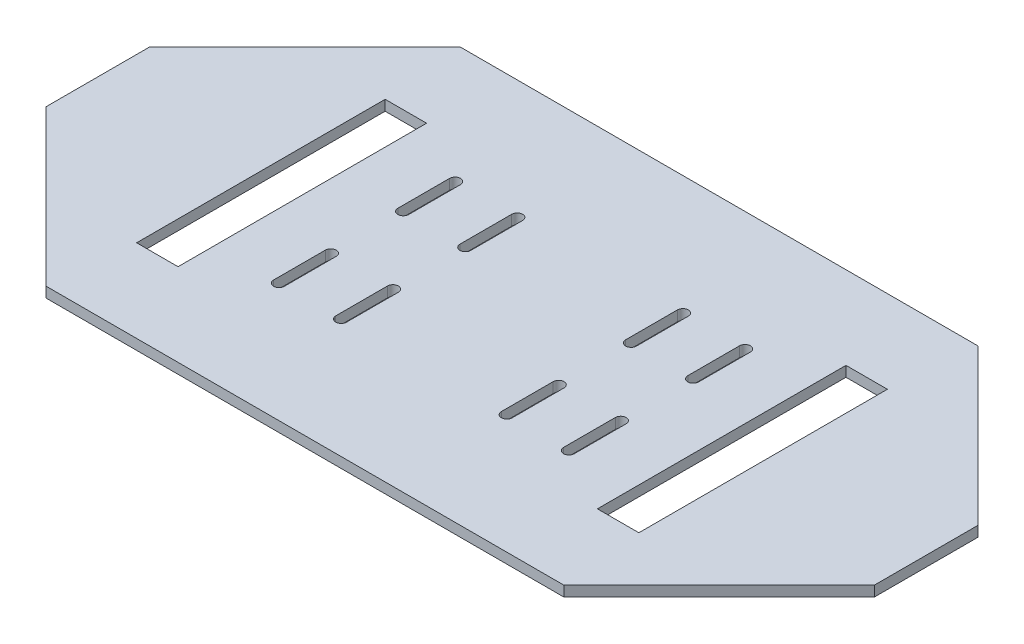
from build123d import *

# Parameters (mm, degrees)
ESQUISSE1_W             = 160
ESQUISSE1_H             = 80
BOSS_EXTRU_1_DEPTH      = 2
ENL_V_MAT_EXTRU_2_DEPTH = 2
ENL_V_MAT_EXTRU_3_DEPTH = 2
ENL_V_MAT_EXTRU_4_REACH = 4
ESQUISSE8_W             = 8
ESQUISSE8_H             = 48


with BuildPart() as part:
    # Esquisse1 → Boss.-Extru.1 (new body)
    with BuildSketch(Plane(origin=(0, 0, 0), x_dir=(1, 0, 0), z_dir=(0, 1, 0))):
        with Locations((80, 40)):
            Rectangle(ESQUISSE1_W, ESQUISSE1_H)
    extrude(amount=BOSS_EXTRU_1_DEPTH)

    # Esquisse2 → Enlèv. mat.-Extru.2 (cut)
    with BuildSketch(Plane(origin=(0, 2, 0), x_dir=(1, 0, 0), z_dir=(0, 1, 0))):
        Polygon((0, 50), (30, 80), (0, 80), align=None)
        Polygon((130, 80), (160, 50), (160, 80), align=None)
        Polygon((130, 0), (160, 30), (160, 0), align=None)
        Polygon((0, 30), (30, 0), (0, 0), align=None)
    extrude(amount=-ENL_V_MAT_EXTRU_2_DEPTH, mode=Mode.SUBTRACT)

    # Esquisse7 → Enlèv. mat.-Extru.3 (cut)
    with BuildSketch(Plane(origin=(0, 2, 0), x_dir=(1, 0, 0), z_dir=(0, 1, 0))):
        with BuildLine():
            Line((62.95, 23), (62.95, 33))
            ThreePointArc((62.95, 33), (64, 34.05), (65.05, 33))
            Line((65.05, 33), (65.05, 23))
            ThreePointArc((65.05, 23), (64, 21.95), (62.95, 23))
        make_face()
        with BuildLine():
            Line((50.95, 23), (50.95, 33))
            ThreePointArc((50.95, 33), (52, 34.05), (53.05, 33))
            Line((53.05, 33), (53.05, 23))
            ThreePointArc((53.05, 23), (52, 21.95), (50.95, 23))
        make_face()
        with BuildLine():
            Line((50.95, 47), (50.95, 57))
            ThreePointArc((50.95, 57), (52, 58.05), (53.05, 57))
            Line((53.05, 57), (53.05, 47))
            ThreePointArc((53.05, 47), (52, 45.95), (50.95, 47))
        make_face()
        with BuildLine():
            Line((62.95, 47), (62.95, 57))
            ThreePointArc((62.95, 57), (64, 58.05), (65.05, 57))
            Line((65.05, 57), (65.05, 47))
            ThreePointArc((65.05, 47), (64, 45.95), (62.95, 47))
        make_face()
        with BuildLine():
            Line((97.05, 47), (97.05, 57))
            ThreePointArc((97.05, 57), (96, 58.05), (94.95, 57))
            Line((94.95, 57), (94.95, 47))
            ThreePointArc((94.95, 47), (96, 45.95), (97.05, 47))
        make_face()
        with BuildLine():
            Line((109.05, 47), (109.05, 57))
            ThreePointArc((109.05, 57), (108, 58.05), (106.95, 57))
            Line((106.95, 57), (106.95, 47))
            ThreePointArc((106.95, 47), (108, 45.95), (109.05, 47))
        make_face()
        with BuildLine():
            Line((109.05, 23), (109.05, 33))
            ThreePointArc((109.05, 33), (108, 34.05), (106.95, 33))
            Line((106.95, 33), (106.95, 23))
            ThreePointArc((106.95, 23), (108, 21.95), (109.05, 23))
        make_face()
        with BuildLine():
            Line((97.05, 23), (97.05, 33))
            ThreePointArc((97.05, 33), (96, 34.05), (94.95, 33))
            Line((94.95, 33), (94.95, 23))
            ThreePointArc((94.95, 23), (96, 21.95), (97.05, 23))
        make_face()
    extrude(amount=-ENL_V_MAT_EXTRU_3_DEPTH, mode=Mode.SUBTRACT)

    # Esquisse8 → Enlèv. mat.-Extru.4 (cut, up to next)
    with BuildSketch(Plane(origin=(0, 2, 0), x_dir=(1, 0, 0), z_dir=(0, 1, 0)), mode=Mode.PRIVATE) as enl_v_mat_extru_4_sk1:
        with Locations((124.5, 40)):
            Rectangle(ESQUISSE8_W, ESQUISSE8_H)
    enl_v_mat_extru_4_tool1 = extrude(enl_v_mat_extru_4_sk1.sketch, amount=-ENL_V_MAT_EXTRU_4_REACH, mode=Mode.PRIVATE) & part.part
    add(enl_v_mat_extru_4_tool1.solids().sort_by_distance((124.5, 2, -40))[0], mode=Mode.SUBTRACT)
    # Esquisse8 → Enlèv. mat.-Extru.4 (cut, up to next)
    with BuildSketch(Plane(origin=(0, 2, 0), x_dir=(1, 0, 0), z_dir=(0, 1, 0)), mode=Mode.PRIVATE) as enl_v_mat_extru_4_sk2:
        with Locations((35.5, 40)):
            Rectangle(ESQUISSE8_W, ESQUISSE8_H)
    enl_v_mat_extru_4_tool2 = extrude(enl_v_mat_extru_4_sk2.sketch, amount=-ENL_V_MAT_EXTRU_4_REACH, mode=Mode.PRIVATE) & part.part
    add(enl_v_mat_extru_4_tool2.solids().sort_by_distance((35.5, 2, -40))[0], mode=Mode.SUBTRACT)


solid = part.part
